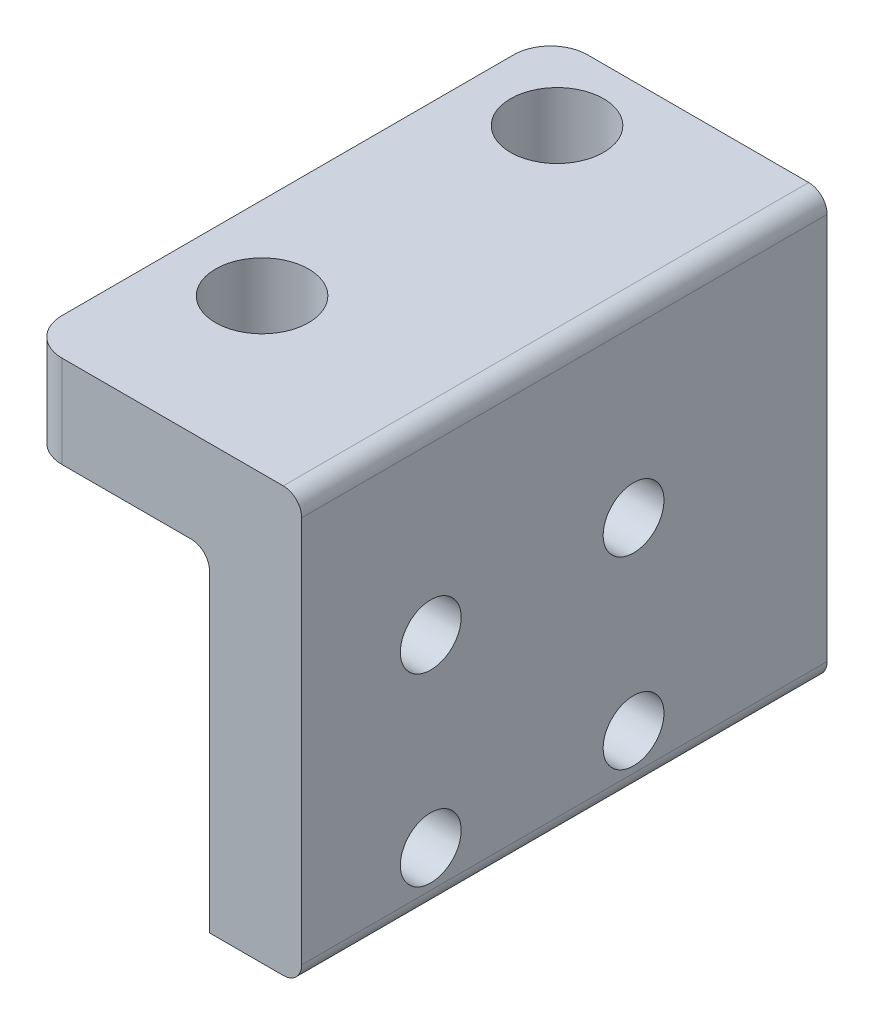
from build123d import *

# Parameters (mm, degrees)
EXTRUDE_1_DEPTH     = 28.5
SKETCH_2_R          = 2.525
CUT_EXTRUDE_1_DEPTH = 28.5
HOLE_WIZARD_M4_1_D  = 3.3
FILLET_1_R          = 2
FILLET_2_R          = 1


with BuildPart() as part:
    # 草图1 → 凸台-拉伸1 (new body)
    with BuildSketch(Plane.XY):
        Polygon((0, 0), (-10, 0), (-10, 5), (5, 5), (5, -18), (0, -18), align=None)
    extrude(amount=EXTRUDE_1_DEPTH)

    # 草图2 → 切除-拉伸1 (cut)
    with BuildSketch(Plane(origin=(0, 5, 0), x_dir=(1, 0, 0), z_dir=(0, 1, 0))):
        with Locations((-5.5, -4.15)):
            Circle(SKETCH_2_R)
        with Locations((-5.5, -20.15)):
            Circle(SKETCH_2_R)
    extrude(amount=-CUT_EXTRUDE_1_DEPTH, mode=Mode.SUBTRACT)

    # M4 螺纹孔1 (through all)
    with Locations(Plane(origin=(0, -5, 10.5), x_dir=(0, -1, 0), z_dir=(-1, 0, 0))):
        with Locations((0, 0), (10, 0), (10, 11), (0, 11)):
            Hole(HOLE_WIZARD_M4_1_D / 2)

    # 圆角1
    fillet_1_edges = [part.edges().sort_by_distance(p)[0] for p in [
        (-10, 2.5, 28.5),
        (-10, 2.5, 0),
    ]]
    fillet(fillet_1_edges, radius=FILLET_1_R)

    # 圆角2
    fillet_2_edges = [part.edges().sort_by_distance(p)[0] for p in [
        (0, 0, 14.25),
        (5, 5, 14.25),
        (5, -18, 14.25),
    ]]
    fillet(fillet_2_edges, radius=FILLET_2_R)


solid = part.part
